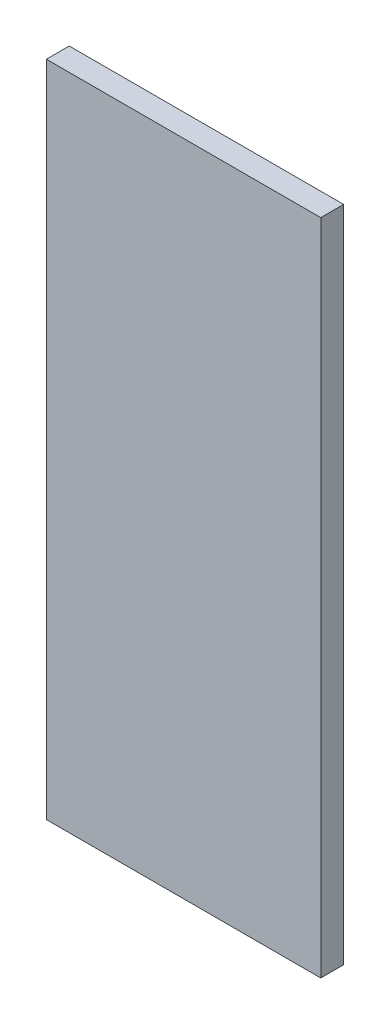
from build123d import *

# Parameters (mm, degrees)
SKETCH2_W           = 38.1
SKETCH2_H           = 3.175
BOSS_EXTRUDE1_DEPTH = 91.44


with BuildPart() as part:
    # Sketch2 → Boss-Extrude1 (new body)
    with BuildSketch(Plane(origin=(0, 0, 0), x_dir=(1, 0, 0), z_dir=(0, 1, 0))):
        with Locations((-58.313358779, -21.447003817)):
            Rectangle(SKETCH2_W, SKETCH2_H)
    extrude(amount=BOSS_EXTRUDE1_DEPTH)


solid = part.part
